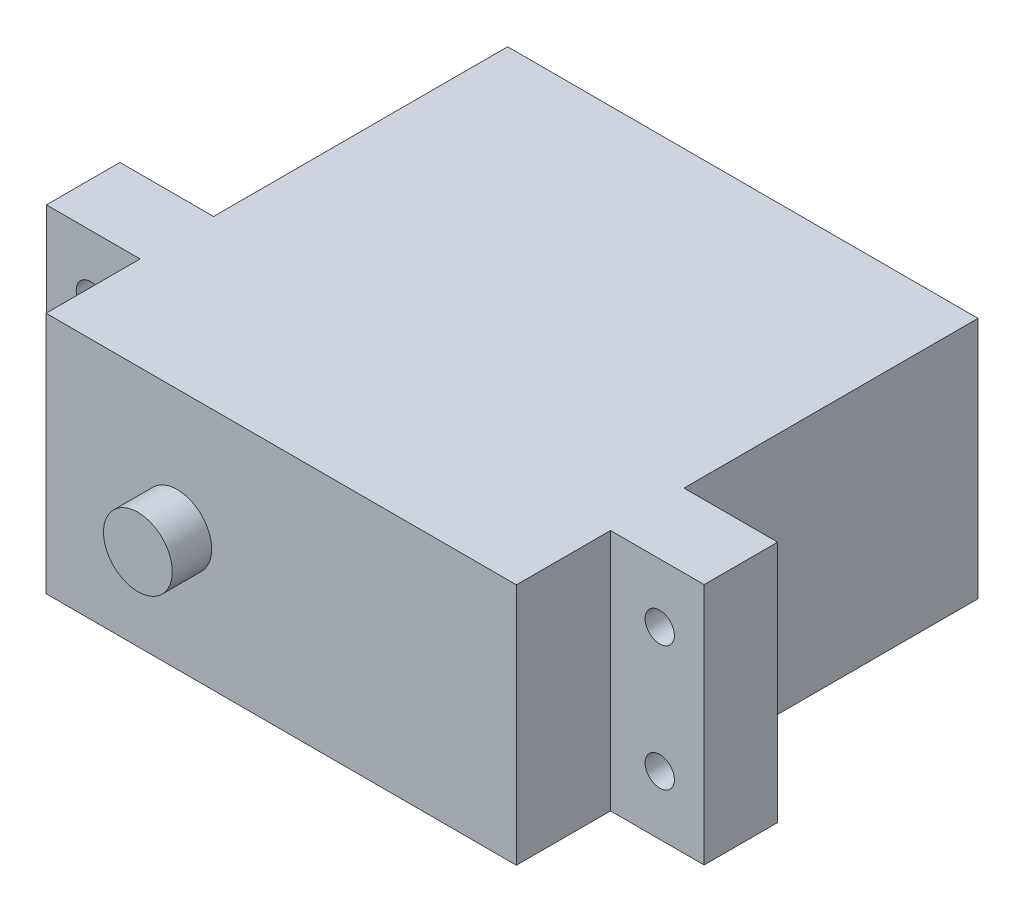
from build123d import *

# Parameters (mm, degrees)
SKETCH1_W                    = 56.8198
SKETCH1_H                    = 20.9804
EXTRUDE1_DEPTH               = 43.2816
SKETCH3_OUTSIDE_W            = 73.708
SKETCH3_OUTSIDE_H            = 37.868
SKETCH3_OUTSIDE_R            = 2.9718
EXTRUDE2_DEPTH               = 3.4036
SKETCH8_W                    = 8.0899
SKETCH8_H                    = 20.9804
EXTRUDE5_DEPTH               = 25.4
F_39_0_0995_DIAMETER_HOLE1_D = 2.5273
SKETCH13_W                   = 8.0899
SKETCH13_H                   = 20.9804
EXTRUDE6_DEPTH               = 8.128


with BuildPart() as part:
    # Sketch1 → Extrude1 (new body)
    with BuildSketch(Plane.XY):
        Rectangle(SKETCH1_W, SKETCH1_H)
    extrude(amount=EXTRUDE1_DEPTH)

    # Sketch3 outside → Extrude2 (cut)
    with BuildSketch(Plane.XY.offset(43.2816)):
        Rectangle(SKETCH3_OUTSIDE_W, SKETCH3_OUTSIDE_H)
        with Locations((-8.9789, 0)):
            Circle(SKETCH3_OUTSIDE_R, mode=Mode.SUBTRACT)
    extrude(amount=-EXTRUDE2_DEPTH, mode=Mode.SUBTRACT)

    # Sketch8 → Extrude5 (cut)
    with BuildSketch(Plane(origin=(0, 0, 0), x_dir=(-1, 0, 0), z_dir=(0, 0, -1))):
        with Locations((-24.36495, 0)):
            Rectangle(SKETCH8_W, SKETCH8_H)
        with Locations((24.36495, 0)):
            Rectangle(SKETCH8_W, SKETCH8_H)
    extrude(amount=-EXTRUDE5_DEPTH, mode=Mode.SUBTRACT)

    # #39 (0.0995) Diameter Hole1 (through all)
    with Locations(Plane(origin=(-24.5745, 5.3975, 39.878), x_dir=(1, 0, 0), z_dir=(0, 0, 1))):
        with Locations((0, 0), (0, -10.795), (49.149, 0), (49.149, -10.795)):
            Hole(F_39_0_0995_DIAMETER_HOLE1_D / 2)

    # Sketch13 → Extrude6 (cut)
    with BuildSketch(Plane.XY.offset(39.878)):
        with Locations((-24.36495, 0)):
            Rectangle(SKETCH13_W, SKETCH13_H)
        with Locations((24.36495, 0)):
            Rectangle(SKETCH13_W, SKETCH13_H)
    extrude(amount=-EXTRUDE6_DEPTH, mode=Mode.SUBTRACT)


solid = part.part
